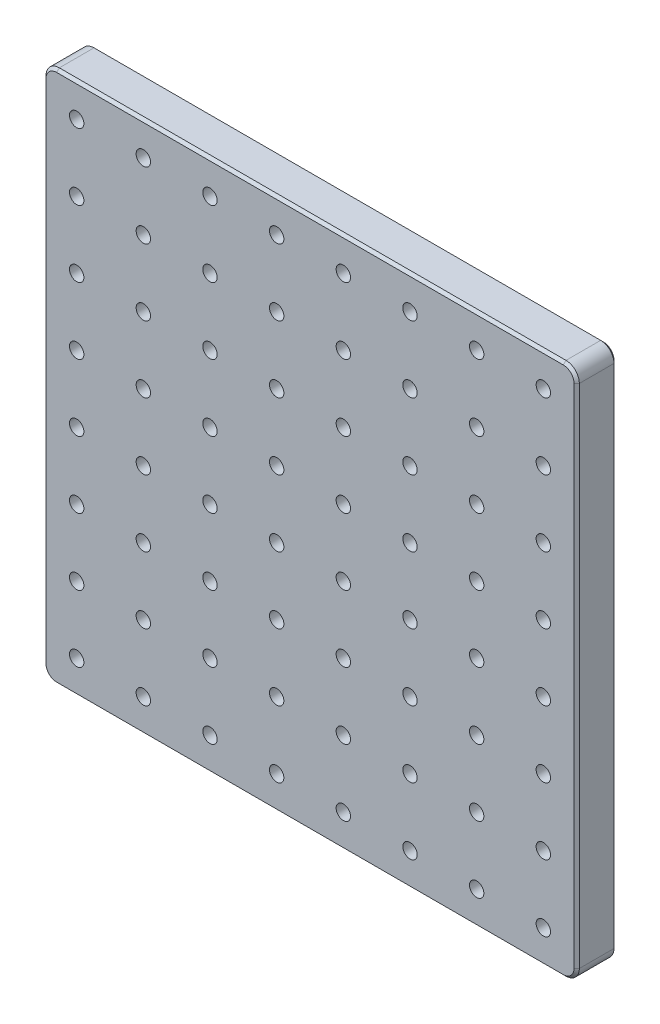
from build123d import *

# Parameters (mm, degrees)
SKETCH1_W            = 400
SKETCH1_H            = 400
BOSS_EXTRUDE1_DEPTH  = 15
LPATTERN1_COUNT      = 8
LPATTERN1_PITCH      = 50
LPATTERN1_COUNT_DIR2 = 8
LPATTERN1_PITCH_DIR2 = 50
FILLET1_R            = 10
CHAMFER1_SIZE        = 2
CHAMFER2_SIZE        = 2


with BuildPart() as part:
    # Sketch1 → Boss-Extrude1 (new body, symmetric)
    with BuildSketch(Plane.XY):
        Rectangle(SKETCH1_W, SKETCH1_H)
    extrude(amount=BOSS_EXTRUDE1_DEPTH, both=True)

    # Sketch2 → M12x1.25 Tapped Hole1 (revolve, cut)
    with BuildSketch(Plane(origin=(-175, 175, 15), x_dir=(0, -1, 0), z_dir=(1, 0, 0))):
        Polygon((0, 0), (0, 33.244647343), (5.4, 30), (5.4, 0), align=None)
    m12x1_25_tapped_hole1 = revolve(axis=Axis((-175, 175, 21.35), (0, 0, -1)), mode=Mode.SUBTRACT)

    # LPattern1: M12x1.25 Tapped Hole1 8 × 8
    with Locations(*[(i * LPATTERN1_PITCH, -j * LPATTERN1_PITCH_DIR2, 0) for i in range(LPATTERN1_COUNT) for j in range(LPATTERN1_COUNT_DIR2) if (i, j) != (0, 0)]):
        add(m12x1_25_tapped_hole1, mode=Mode.SUBTRACT)

    # Fillet1
    fillet1_edges = [part.edges().sort_by_distance(p)[0] for p in [
        (200, -200, 0),
        (-200, -200, 0),
        (-200, 200, 0),
        (200, 200, 0),
    ]]
    fillet(fillet1_edges, radius=FILLET1_R)

    # Chamfer1
    chamfer1_edges = [part.edges().sort_by_distance(p)[0] for p in [
        (200, 0, 15),
        (0, -200, 15),
        (0, 200, 15),
        (-200, 0, 15),
        (-197.071067812, -197.071067812, 15),
        (-197.071067812, 197.071067812, 15),
        (197.071067812, 197.071067812, 15),
        (197.071067812, -197.071067812, 15),
    ]]
    chamfer(chamfer1_edges, length=CHAMFER1_SIZE)

    # Chamfer2
    chamfer2_edges = [part.edges().sort_by_distance(p)[0] for p in [
        (200, 0, -15),
        (0, -200, -15),
        (-200, 0, -15),
        (0, 200, -15),
        (-197.071067812, -197.071067812, -15),
        (-197.071067812, 197.071067812, -15),
        (197.071067812, 197.071067812, -15),
        (197.071067812, -197.071067812, -15),
    ]]
    chamfer(chamfer2_edges, length=CHAMFER2_SIZE)


solid = part.part
